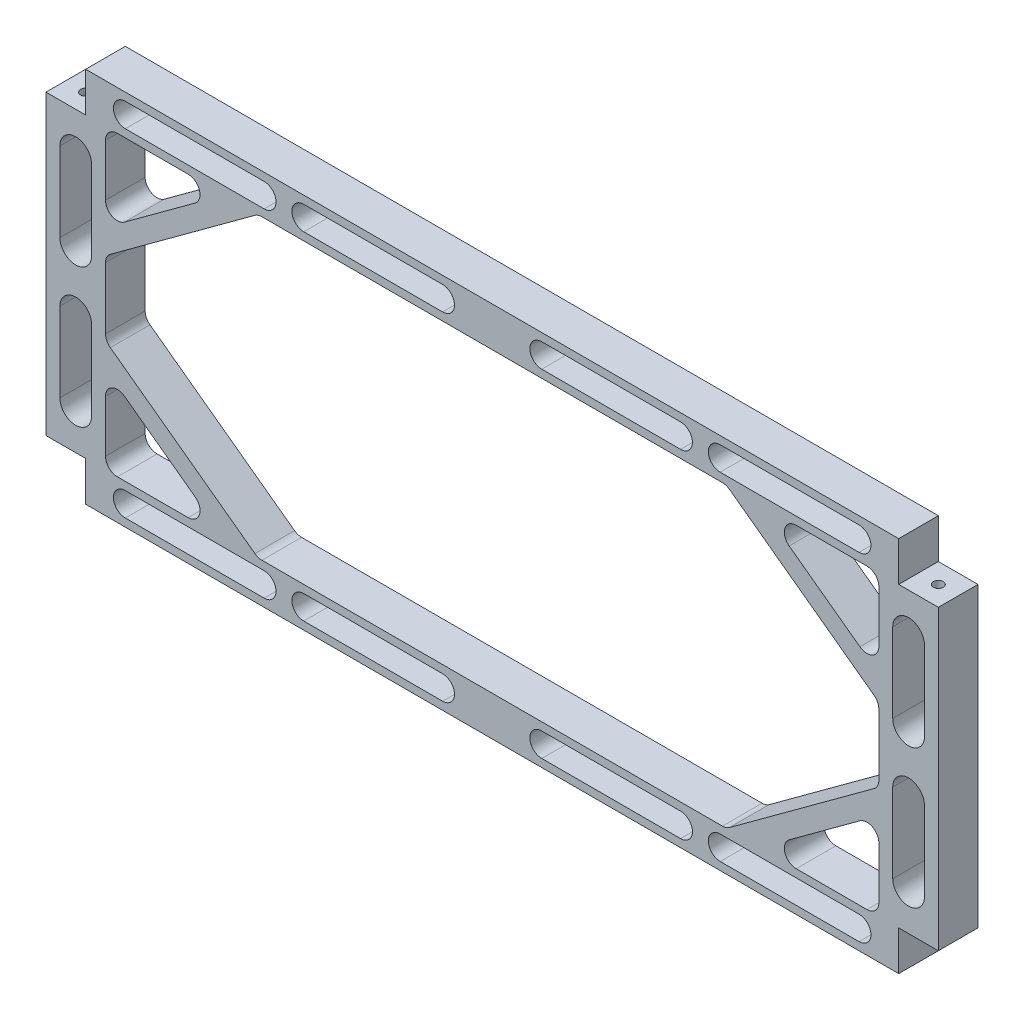
from build123d import *

# Parameters (mm, degrees)
BOSS_EXTRUDE1_DEPTH   = 10
FILLET1_R             = 3
M3_TAPPED_HOLE2_D     = 2.5
M3_TAPPED_HOLE2_DEPTH = 15
M3_TAPPED_HOLE2_TIP   = 0.751075774


with BuildPart() as part:
    # Sketch1 → Boss-Extrude1 (new body)
    with BuildSketch(Plane.XY):
        Polygon((10, 10), (10, 0), (215, 0), (215, 10), (225, 10), (225, 85), (215, 85), (215, 95), (10, 95), (10, 85), (0, 85), (0, 10), align=None)
        with BuildLine():
            Line((20, 8), (55, 8))
            ThreePointArc((55, 8), (58, 5), (55, 2))
            Line((55, 2), (20, 2))
            ThreePointArc((20, 2), (17, 5), (20, 8))
        make_face(mode=Mode.SUBTRACT)
        with BuildLine():
            Line((65, 8), (100, 8))
            ThreePointArc((100, 8), (103, 5), (100, 2))
            Line((100, 2), (65, 2))
            ThreePointArc((65, 2), (62, 5), (65, 8))
        make_face(mode=Mode.SUBTRACT)
        with BuildLine():
            Line((3.5, 20), (3.5, 40))
            ThreePointArc((3.5, 40), (7.5, 44), (11.5, 40))
            Line((11.5, 40), (11.5, 20))
            ThreePointArc((11.5, 20), (7.5, 16), (3.5, 20))
        make_face(mode=Mode.SUBTRACT)
        with BuildLine():
            ThreePointArc((160, 8), (163, 5), (160, 2))
            Line((160, 2), (125, 2))
            ThreePointArc((125, 2), (122, 5), (125, 8))
            Line((125, 8), (160, 8))
        make_face(mode=Mode.SUBTRACT)
        with BuildLine():
            ThreePointArc((205, 8), (208, 5), (205, 2))
            Line((205, 2), (170, 2))
            ThreePointArc((170, 2), (167, 5), (170, 8))
            Line((170, 8), (205, 8))
        make_face(mode=Mode.SUBTRACT)
        with BuildLine():
            Line((213.5, 20), (213.5, 40))
            ThreePointArc((213.5, 40), (217.5, 44), (221.5, 40))
            Line((221.5, 40), (221.5, 20))
            ThreePointArc((221.5, 20), (217.5, 16), (213.5, 20))
        make_face(mode=Mode.SUBTRACT)
        with BuildLine():
            Line((3.5, 55), (3.5, 75))
            ThreePointArc((3.5, 75), (7.5, 79), (11.5, 75))
            Line((11.5, 75), (11.5, 55))
            ThreePointArc((11.5, 55), (7.5, 51), (3.5, 55))
        make_face(mode=Mode.SUBTRACT)
        with BuildLine():
            Line((20, 93), (55, 93))
            ThreePointArc((55, 93), (58, 90), (55, 87))
            Line((55, 87), (20, 87))
            ThreePointArc((20, 87), (17, 90), (20, 93))
        make_face(mode=Mode.SUBTRACT)
        with BuildLine():
            Line((65, 93), (100, 93))
            ThreePointArc((100, 93), (103, 90), (100, 87))
            Line((100, 87), (65, 87))
            ThreePointArc((65, 87), (62, 90), (65, 93))
        make_face(mode=Mode.SUBTRACT)
        Polygon((15, 63), (15, 85), (45, 85), align=None, mode=Mode.SUBTRACT)
        Polygon((15, 56.799641587), (53.455034199, 85), (171.544965801, 85), (210, 56.799641587), (210, 38.200358413), (171.544965801, 10), (53.455034199, 10), (15, 38.200358413), align=None, mode=Mode.SUBTRACT)
        Polygon((210, 32), (210, 10), (180, 10), align=None, mode=Mode.SUBTRACT)
        Polygon((180, 85), (210, 85), (210, 63), align=None, mode=Mode.SUBTRACT)
        Polygon((45, 10), (15, 10), (15, 32), align=None, mode=Mode.SUBTRACT)
        with BuildLine():
            Line((213.5, 55), (213.5, 75))
            ThreePointArc((213.5, 75), (217.5, 79), (221.5, 75))
            Line((221.5, 75), (221.5, 55))
            ThreePointArc((221.5, 55), (217.5, 51), (213.5, 55))
        make_face(mode=Mode.SUBTRACT)
        with BuildLine():
            Line((125, 93), (160, 93))
            ThreePointArc((160, 93), (163, 90), (160, 87))
            Line((160, 87), (125, 87))
            ThreePointArc((125, 87), (122, 90), (125, 93))
        make_face(mode=Mode.SUBTRACT)
        with BuildLine():
            Line((170, 93), (205, 93))
            ThreePointArc((205, 93), (208, 90), (205, 87))
            Line((205, 87), (170, 87))
            ThreePointArc((170, 87), (167, 90), (170, 93))
        make_face(mode=Mode.SUBTRACT)
    extrude(amount=BOSS_EXTRUDE1_DEPTH)

    # Fillet1
    fillet1_edges = [part.edges().sort_by_distance(p)[0] for p in [
        (15, 32, 5),
        (15, 10, 5),
        (45, 10, 5),
        (180, 10, 5),
        (210, 10, 5),
        (210, 32, 5),
        (210, 63, 5),
        (210, 85, 5),
        (180, 85, 5),
        (15, 85, 5),
        (15, 63, 5),
        (45, 85, 5),
        (53.455034199, 85, 5),
        (15, 56.799641587, 5),
        (15, 38.200358413, 5),
        (53.455034199, 10, 5),
        (171.544965801, 10, 5),
        (210, 38.200358413, 5),
        (210, 56.799641587, 5),
        (171.544965801, 85, 5),
    ]]
    fillet(fillet1_edges, radius=FILLET1_R)

    # M3 Tapped Hole2
    with Locations(Plane(origin=(0, 85, 0), x_dir=(1, 0, 0), z_dir=(0, 1, 0))):
        with Locations((220, -5), (5, -5)):
            Hole(M3_TAPPED_HOLE2_D / 2, depth=M3_TAPPED_HOLE2_DEPTH)
            with Locations((0, 0, -(M3_TAPPED_HOLE2_DEPTH + M3_TAPPED_HOLE2_TIP / 2))):  # 118° drill point
                Cone(0, M3_TAPPED_HOLE2_D / 2, M3_TAPPED_HOLE2_TIP, mode=Mode.SUBTRACT)


solid = part.part
